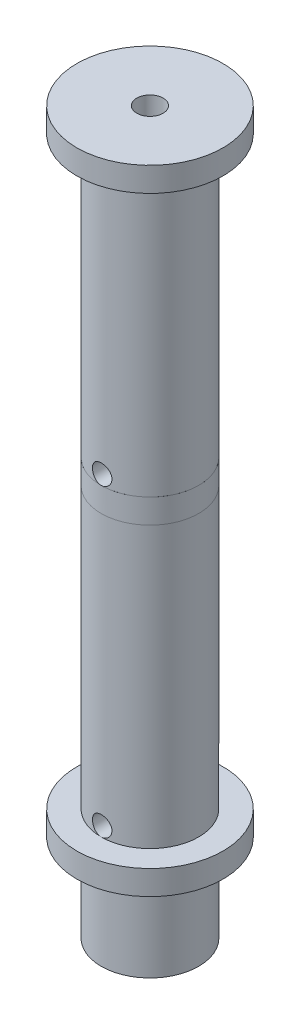
from build123d import *

# Parameters (mm, degrees)
SKETCH1_R                = 10
BOSS_EXTRUDE1_DEPTH      = 18
SKETCH2_R                = 15
BOSS_EXTRUDE2_DEPTH      = 5
SKETCH3_R                = 1.75
CUT_EXTRUDE1_DEPTH       = 120
SKETCH4_R                = 10
BOSS_EXTRUDE3_DEPTH      = 120
SKETCH6_R                = 5
CUT_EXTRUDE3_DEPTH       = 120
SKETCH5_R                = 15
BOSS_EXTRUDE4_DEPTH      = 5
SKETCH7_R                = 2.7
CUT_EXTRUDE4_DEPTH       = 149.0000001
SKETCH9_R                = 10.005
BOSS_EXTRUDE5_DEPTH      = 2.5
BOSS_EXTRUDE5_DEPTH_BACK = 2.5
SKETCH10_R               = 2
CUT_EXTRUDE5_DEPTH       = 16
CUT_EXTRUDE5_DEPTH_BACK  = 16


with BuildPart() as part:
    # Sketch1 → Boss-Extrude1 (new body)
    with BuildSketch(Plane(origin=(0, 0, 0), x_dir=(1, 0, 0), z_dir=(0, 1, 0))):
        Circle(SKETCH1_R)
        Polygon((-3.457767936, -6.13654416), (3.585519166, -6.062786953), (7.043287102, 0.073757207), (3.457767936, 6.13654416), (-3.585519166, 6.062786953), (-7.043287102, -0.073757207), align=None, mode=Mode.SUBTRACT)
    extrude(amount=BOSS_EXTRUDE1_DEPTH)

    # Sketch2 → Boss-Extrude2 (add)
    with BuildSketch(Plane(origin=(0, 18, 0), x_dir=(1, 0, 0), z_dir=(0, 1, 0))):
        Circle(SKETCH2_R)
    extrude(amount=BOSS_EXTRUDE2_DEPTH)

    # Sketch3 → Cut-Extrude1 (cut)
    with BuildSketch(Plane(origin=(-5.314403134, 0, -2.994514873), x_dir=(0.490904078, 0, -0.871213629), z_dir=(0.871213629, 0, 0.490904078))):
        with Locations((0, 5)):
            Circle(SKETCH3_R)
    extrude(amount=-CUT_EXTRUDE1_DEPTH, mode=Mode.SUBTRACT)

    # Sketch4 → Boss-Extrude3 (add)
    with BuildSketch(Plane(origin=(0, 23, 0), x_dir=(1, 0, 0), z_dir=(0, 1, 0))):
        Circle(SKETCH4_R)
    extrude(amount=BOSS_EXTRUDE3_DEPTH)

    # Sketch6 → Cut-Extrude3 (cut)
    with BuildSketch(Plane(origin=(0, 143, 0), x_dir=(1, 0, 0), z_dir=(0, 1, 0))):
        Circle(SKETCH6_R)
    extrude(amount=-CUT_EXTRUDE3_DEPTH, mode=Mode.SUBTRACT)

    # Sketch5 → Boss-Extrude4 (add)
    with BuildSketch(Plane(origin=(0, 143, 0), x_dir=(1, 0, 0), z_dir=(0, 1, 0))):
        Circle(SKETCH5_R)
    extrude(amount=BOSS_EXTRUDE4_DEPTH)

    # Sketch7 → Cut-Extrude4 (cut, through all)
    with BuildSketch(Plane(origin=(0, 148, 0), x_dir=(1, 0, 0), z_dir=(0, 1, 0))):
        Circle(SKETCH7_R)
    extrude(amount=-CUT_EXTRUDE4_DEPTH, mode=Mode.SUBTRACT)

    # Sketch9 → Boss-Extrude5 (add, two sides)
    with BuildSketch(Plane(origin=(0, 83, 0), x_dir=(1, 0, 0), z_dir=(0, 1, 0))) as boss_extrude5_sk:
        Circle(SKETCH9_R)
    extrude(amount=BOSS_EXTRUDE5_DEPTH)
    extrude(boss_extrude5_sk.sketch, amount=-BOSS_EXTRUDE5_DEPTH_BACK)

    # Sketch10 → Cut-Extrude5 (cut, two sides)
    with BuildSketch(Plane.XY) as cut_extrude5_sk:
        with Locations((0, 25)):
            Circle(SKETCH10_R)
        with Locations((0, 87.5)):
            Circle(SKETCH10_R)
    extrude(amount=CUT_EXTRUDE5_DEPTH, mode=Mode.SUBTRACT)
    extrude(cut_extrude5_sk.sketch, amount=-CUT_EXTRUDE5_DEPTH_BACK, mode=Mode.SUBTRACT)


solid = part.part
